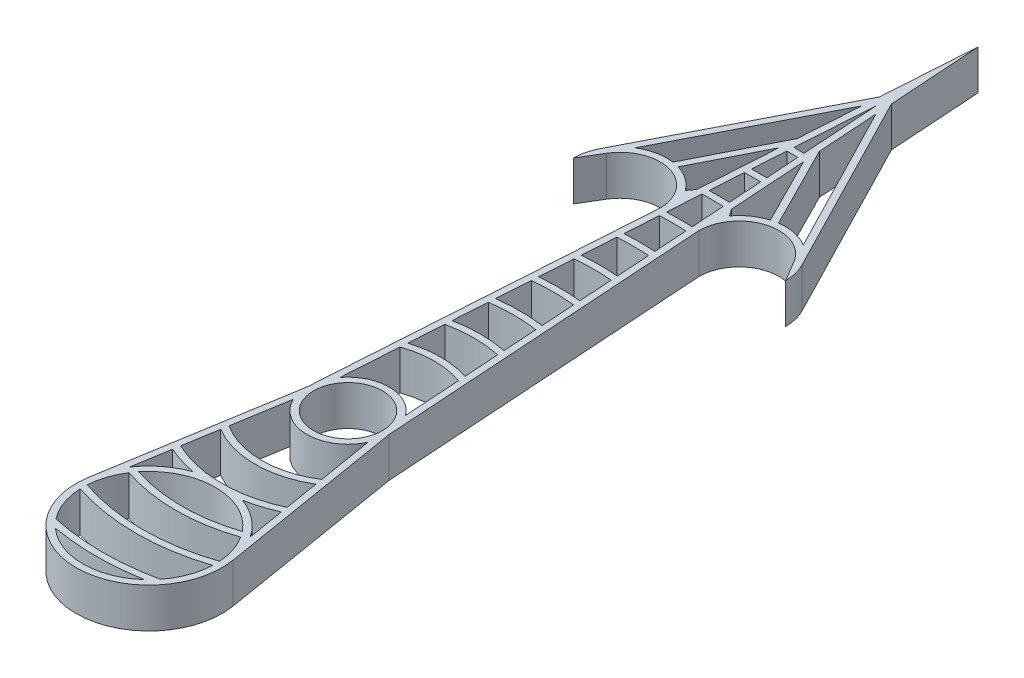
from build123d import *

# Parameters (mm, degrees)
SKETCH1_R           = 5.2
SKETCH1_R_2         = 10
BOSS_EXTRUDE1_DEPTH = 6
BOSS_EXTRUDE2_DEPTH = 6
BOSS_EXTRUDE4_DEPTH = 6


with BuildPart() as part:
    # Sketch1 → Boss-Extrude1 (new body)
    with BuildSketch(Plane(origin=(0, 0, 0), x_dir=(1, 0, 0), z_dir=(0, 1, 0))):
        with BuildLine():
            Line((-6.2, 0), (0, 95))
            Line((0, 95), (6.2, 0))
            Line((6.2, 0), (10.853330552, -28.209688314))
            ThreePointArc((10.853330552, -28.209688314), (0, -41), (-10.853330552, -28.209688314))
            Line((-10.853330552, -28.209688314), (-6.2, 0))
        make_face()
        with Locations(Location((0, 0, 0), (0, 0, 270))):
            Circle(SKETCH1_R, mode=Mode.SUBTRACT)
        with Locations(Location((0, -30, 0), (0, 0, 270))):
            Circle(SKETCH1_R_2, mode=Mode.SUBTRACT)
        with BuildLine():
            Line((-9.120824245, -23.850970395), (-5.618811795, -2.620868943))
            ThreePointArc((-5.618811795, -2.620868943), (0, -6.2), (5.618811795, -2.620868943))
            Line((5.618811795, -2.620868943), (9.120824245, -23.850970395))
            ThreePointArc((9.120824245, -23.850970395), (0, -19), (-9.120824245, -23.850970395))
        make_face(mode=Mode.SUBTRACT)
        with BuildLine():
            Line((-4.954626817, 3.727153486), (0, 79.644822449))
            Line((0, 79.644822449), (4.954626817, 3.727153486))
            ThreePointArc((4.954626817, 3.727153486), (0, 6.2), (-4.954626817, 3.727153486))
        make_face(mode=Mode.SUBTRACT)
    extrude(amount=BOSS_EXTRUDE1_DEPTH)

    # Sketch3 → Boss-Extrude2 (add)
    with BuildSketch(Plane(origin=(0, 0, 0), x_dir=(1, 0, 0), z_dir=(0, 1, 0))):
        with BuildLine():
            Line((4.841629208, 13.136157224), (4.913448664, 12.035697829))
            ThreePointArc((4.913448664, 12.035697829), (0, 13), (-4.913448664, 12.035697829))
            Line((-4.913448664, 12.035697829), (-4.841629208, 13.136157224))
            ThreePointArc((-4.841629208, 13.136157224), (0, 14), (4.841629208, 13.136157224))
        make_face()
        with BuildLine():
            Line((4.426036681, 19.504107242), (4.494123165, 18.460846594))
            ThreePointArc((4.494123165, 18.460846594), (0, 19), (-4.494123165, 18.460846594))
            Line((-4.494123165, 18.460846594), (-4.426036681, 19.504107242))
            ThreePointArc((-4.426036681, 19.504107242), (0, 20), (4.426036681, 19.504107242))
        make_face()
        with BuildLine():
            Line((4.022524974, 25.686947908), (4.089332805, 24.663279531))
            ThreePointArc((4.089332805, 24.663279531), (0, 25), (-4.089332805, 24.663279531))
            Line((-4.089332805, 24.663279531), (-4.022524974, 25.686947908))
            ThreePointArc((-4.022524974, 25.686947908), (0, 26), (4.022524974, 25.686947908))
        make_face()
        with BuildLine():
            Line((3.623950699, 31.794134386), (3.690163565, 30.779582402))
            ThreePointArc((3.690163565, 30.779582402), (0, 31), (-3.690163565, 30.779582402))
            Line((-3.690163565, 30.779582402), (-3.623950699, 31.794134386))
            ThreePointArc((-3.623950699, 31.794134386), (0, 32), (3.623950699, 31.794134386))
        make_face()
        with BuildLine():
            Line((3.227899864, 37.862655249), (3.293786636, 36.853099864))
            ThreePointArc((3.293786636, 36.853099864), (0, 37), (-3.293786636, 36.853099864))
            Line((-3.293786636, 36.853099864), (-3.227899864, 37.862655249))
            ThreePointArc((-3.227899864, 37.862655249), (0, 38), (3.227899864, 37.862655249))
        make_face()
        with BuildLine():
            ThreePointArc((2.899005539, 42.902165061), (0, 43), (-2.899005539, 42.902165061))
            Line((-2.899005539, 42.902165061), (-2.833317095, 43.908681536))
            ThreePointArc((-2.833317095, 43.908681536), (0, 44), (2.833317095, 43.908681536))
            Line((2.833317095, 43.908681536), (2.899005539, 42.902165061))
        make_face()
        with BuildLine():
            ThreePointArc((2.505223913, 48.935915779), (0, 49), (-2.505223913, 48.935915779))
            Line((-2.505223913, 48.935915779), (-2.439665173, 49.94044487))
            ThreePointArc((-2.439665173, 49.94044487), (0, 50), (2.439665173, 49.94044487))
            Line((2.439665173, 49.94044487), (2.505223913, 48.935915779))
        make_face()
        with BuildLine():
            ThreePointArc((2.112110327, 54.959430401), (0, 55), (-2.112110327, 54.959430401))
            Line((-2.112110327, 54.959430401), (-2.046641092, 55.962588041))
            ThreePointArc((-2.046641092, 55.962588041), (0, 56), (2.046641092, 55.962588041))
            Line((2.046641092, 55.962588041), (2.112110327, 54.959430401))
        make_face()
        with BuildLine():
            ThreePointArc((1.719465589, 60.97576107), (0, 61), (-1.719465589, 60.97576107))
            Line((-1.719465589, 60.97576107), (-1.654060735, 61.977932227))
            ThreePointArc((-1.654060735, 61.977932227), (0, 62), (1.654060735, 61.977932227))
            Line((1.654060735, 61.977932227), (1.719465589, 60.97576107))
        make_face()
        with BuildLine():
            ThreePointArc((1.327162667, 66.986854227), (0, 67), (-1.327162667, 66.986854227))
            Line((-1.327162667, 66.986854227), (-1.261805677, 67.988291981))
            ThreePointArc((-1.261805677, 67.988291981), (0, 68), (1.261805677, 67.988291981))
            Line((1.261805677, 67.988291981), (1.327162667, 66.986854227))
        make_face()
        with BuildLine():
            Line((-7.629550902, -11.738396528), (-7.450533577, -10.653147395))
            ThreePointArc((-7.450533577, -10.653147395), (0, -13), (7.450533577, -10.653147395))
            Line((7.450533577, -10.653147395), (7.629550902, -11.738396528))
            ThreePointArc((7.629550902, -11.738396528), (0, -14), (-7.629550902, -11.738396528))
        make_face()
        with BuildLine():
            Line((-8.666516131, -18.024746826), (-8.496550368, -16.994370593))
            ThreePointArc((-8.496550368, -16.994370593), (0, -19), (8.496550368, -16.994370593))
            Line((8.496550368, -16.994370593), (8.666516131, -18.024746826))
            ThreePointArc((8.666516131, -18.024746826), (0, -20), (-8.666516131, -18.024746826))
        make_face()
        with BuildLine():
            ThreePointArc((-8.308002125, -23.579166667), (-8.614654406, -23.996856701), (-8.900326734, -24.429166667))
            ThreePointArc((-8.900326734, -24.429166667), (0, -26), (8.900326734, -24.429166667))
            ThreePointArc((8.900326734, -24.429166667), (8.614654406, -23.996856701), (8.308002125, -23.579166667))
            ThreePointArc((8.308002125, -23.579166667), (0, -25), (-8.308002125, -23.579166667))
        make_face()
        with BuildLine():
            ThreePointArc((-10.467866671, -29.179166667), (0, -31), (10.467866671, -29.179166667))
            ThreePointArc((10.467866671, -29.179166667), (10.495821222, -29.703795885), (10.497498875, -30.229166667))
            ThreePointArc((10.497498875, -30.229166667), (0, -32), (-10.497498875, -30.229166667))
            ThreePointArc((-10.497498875, -30.229166667), (-10.495821222, -29.703795885), (-10.467866671, -29.179166667))
        make_face()
        with BuildLine():
            ThreePointArc((-8.631313108, -35.979166667), (0, -37), (8.631313108, -35.979166667))
            ThreePointArc((8.631313108, -35.979166667), (8.147195247, -36.6236855), (7.61506069, -37.229166667))
            ThreePointArc((7.61506069, -37.229166667), (0, -38), (-7.61506069, -37.229166667))
            ThreePointArc((-7.61506069, -37.229166667), (-8.147195247, -36.6236855), (-8.631313108, -35.979166667))
        make_face()
    extrude(amount=BOSS_EXTRUDE2_DEPTH)

    # Sketch5 → Boss-Extrude4 (add)
    with BuildSketch(Plane(origin=(0, 0, 0), x_dir=(1, 0, 0), z_dir=(0, 1, 0))):
        with BuildLine():
            Line((14.142215569, 53.100289487), (16, 50))
            ThreePointArc((16, 50), (15.802513368, 51.654776335), (15.221146562, 53.216601654))
            ThreePointArc((15.221146562, 53.216601654), (14.136998404, 54.76748473), (12.678547514, 55.973111763))
            ThreePointArc((12.678547514, 55.973111763), (10.40739911, 56.882764317), (7.962047997, 56.959189304))
            ThreePointArc((7.962047997, 56.959189304), (7.45389818, 56.86653646), (6.953920906, 56.73683098))
            ThreePointArc((6.953920906, 56.73683098), (5.366056739, 56.038714585), (3.997401273, 54.973134308))
            ThreePointArc((3.997401273, 54.973134308), (3.646986673, 54.596241795), (3.325075946, 54.194729849))
            ThreePointArc((3.325075946, 54.194729849), (2.72869668, 53.241749875), (2.291814027, 52.205905965))
            Line((2.291814027, 52.205905965), (2.435778417, 50))
            Line((2.435778417, 50), (2.936842105, 50))
            ThreePointArc((2.936842105, 50), (7.360037623, 55.813178764), (14.142215569, 53.100289487))
        make_face()
        with BuildLine():
            ThreePointArc((6.953920906, 56.73683098), (7.45389818, 56.86653646), (7.962047997, 56.959189304))
            Line((7.962047997, 56.959189304), (1.095242719, 70.540466335))
            Line((1.095242719, 70.540466335), (1.261318946, 67.995749955))
            Line((1.261318946, 67.995749955), (6.953920906, 56.73683098))
        make_face()
        with BuildLine():
            ThreePointArc((12.678547514, 55.973111763), (14.136998404, 54.76748473), (15.221146562, 53.216601654))
            Line((15.221146562, 53.216601654), (0.337667462, 82.148474304))
            Line((0.337667462, 82.148474304), (0.501063689, 79.644822449))
            Line((0.501063689, 79.644822449), (12.678547514, 55.973111763))
        make_face()
        with BuildLine():
            Line((2.045589816, 55.978696296), (2.291814027, 52.205905965))
            ThreePointArc((2.291814027, 52.205905965), (2.72869668, 53.241749875), (3.325075946, 54.194729849))
            Line((3.325075946, 54.194729849), (2.045589816, 55.978696296))
        make_face()
    boss_extrude4 = extrude(amount=BOSS_EXTRUDE4_DEPTH)

    # Mirror1: Boss-Extrude4 across plane
    add(boss_extrude4.mirror(Plane(origin=(0, 0, 0), x_dir=(0, 0, 1), z_dir=(1, 0, 0))))


solid = part.part
